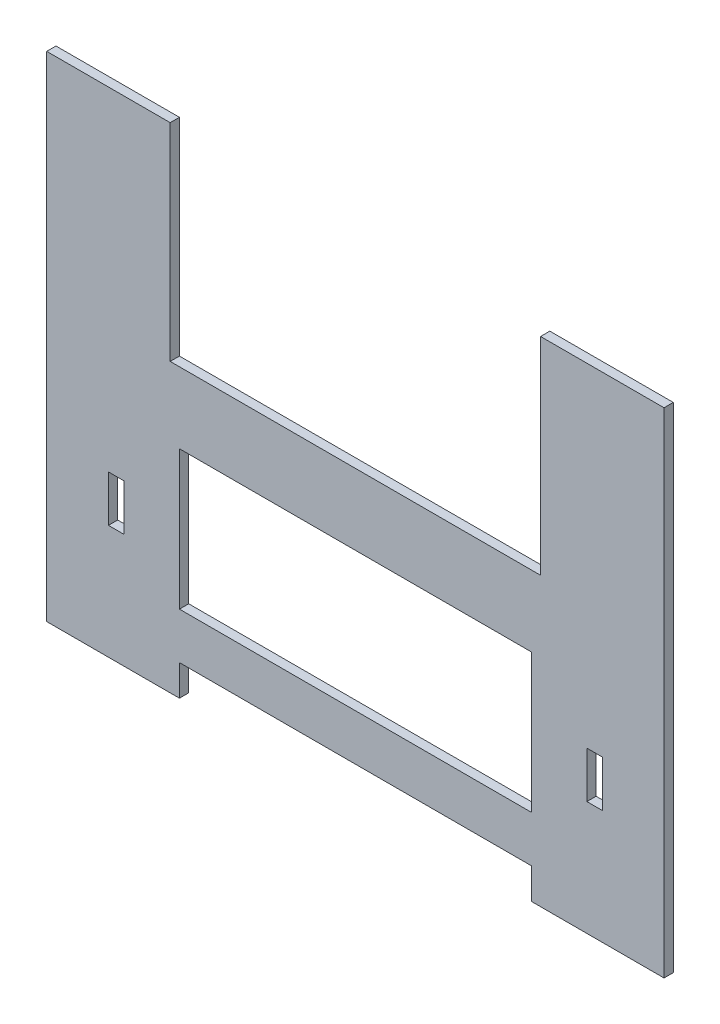
from build123d import *

# Parameters (mm, degrees)
SKETCH_2_W          = 114
SKETCH_2_H          = 45
EXTRUDE_1_DEPTH     = 3
SKETCH_3_W          = 5
SKETCH_3_H          = 15
CUT_EXTRUDE_1_DEPTH = 10


with BuildPart() as part:
    # 草图2 → 凸台-拉伸1 (new body)
    with BuildSketch(Plane.XY):
        Polygon((60, 67), (60, 0), (-60, 0), (-60, 67), (-100, 67), (-100, -93), (-57, -93), (-57, -83), (57, -83), (57, -93), (100, -93), (100, 67), align=None)
        with Locations((0, -45.5)):
            Rectangle(SKETCH_2_W, SKETCH_2_H, mode=Mode.SUBTRACT)
    extrude(amount=EXTRUDE_1_DEPTH)

    # 草图3 → 切除-拉伸1 (cut)
    with BuildSketch(Plane.XY.offset(3)):
        with Locations((-77.5, -48.5)):
            Rectangle(SKETCH_3_W, SKETCH_3_H)
        with Locations((77.5, -48.5)):
            Rectangle(SKETCH_3_W, SKETCH_3_H)
    extrude(amount=-CUT_EXTRUDE_1_DEPTH, mode=Mode.SUBTRACT)


solid = part.part
